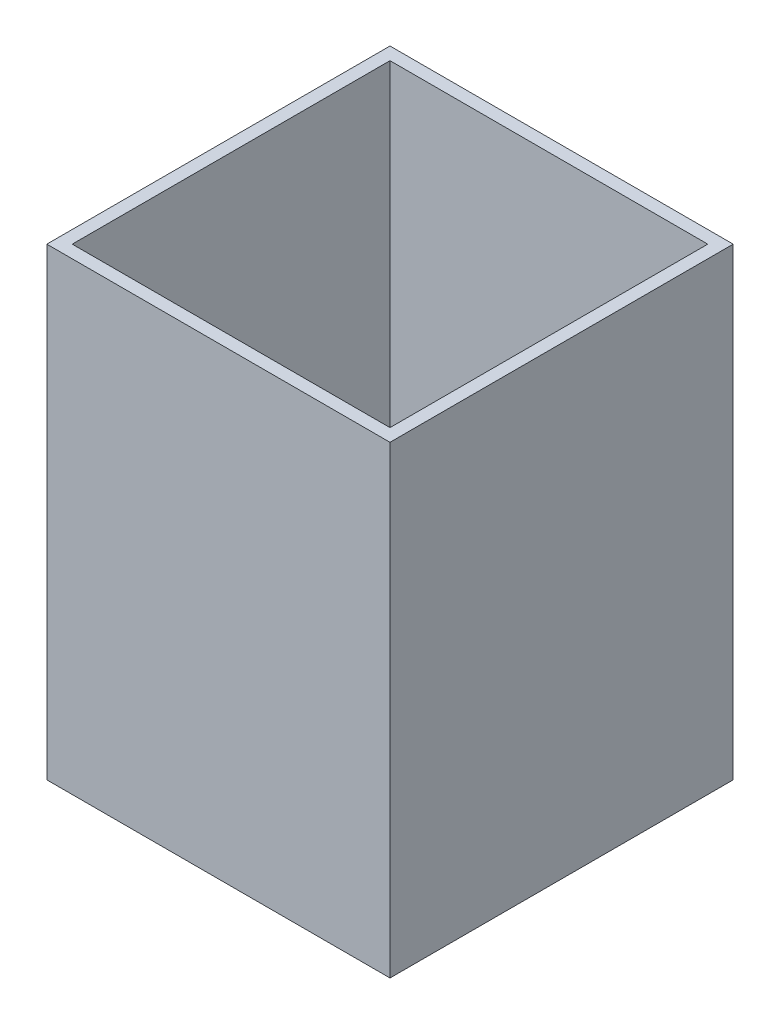
from build123d import *

# Parameters (mm, degrees)
SKETCH1_W           = 54
SKETCH1_H           = 54
SKETCH1_W_2         = 50
SKETCH1_H_2         = 50
BOSS_EXTRUDE1_DEPTH = 22
SKETCH2_W           = 54
SKETCH2_H           = 54
BOSS_EXTRUDE2_DEPTH = 1
SKETCH3_R           = 6
CUT_EXTRUDE1_DEPTH  = 24
SKETCH4_W           = 2
SKETCH4_H           = 50
SKETCH4_H_2         = 2
SKETCH4_W_2         = 50
BOSS_EXTRUDE3_DEPTH = 50


with BuildPart() as part:
    # Sketch1 → Boss-Extrude1 (new body)
    with BuildSketch(Plane(origin=(0, 0, 0), x_dir=(1, 0, 0), z_dir=(0, 1, 0))):
        Rectangle(SKETCH1_W, SKETCH1_H)
        Rectangle(SKETCH1_W_2, SKETCH1_H_2, mode=Mode.SUBTRACT)
    extrude(amount=BOSS_EXTRUDE1_DEPTH)

    # Sketch2 → Boss-Extrude2 (add)
    with BuildSketch(Plane(origin=(0, 22, 0), x_dir=(1, 0, 0), z_dir=(0, 1, 0))):
        Rectangle(SKETCH2_W, SKETCH2_H)
    extrude(amount=BOSS_EXTRUDE2_DEPTH)

    # Sketch3 → Cut-Extrude1 (cut, through all)
    with BuildSketch(Plane(origin=(0, 23, 0), x_dir=(1, 0, 0), z_dir=(0, 1, 0))):
        Circle(SKETCH3_R)
    extrude(amount=-CUT_EXTRUDE1_DEPTH, mode=Mode.SUBTRACT)

    # Sketch4 → Boss-Extrude3 (add)
    with BuildSketch(Plane(origin=(0, 23, 0), x_dir=(1, 0, 0), z_dir=(0, 1, 0))):
        with Locations((-26, 0)):
            Rectangle(SKETCH4_W, SKETCH4_H)
        with Locations((-26, -26)):
            Rectangle(SKETCH4_W, SKETCH4_H_2)
        with Locations((0, -26)):
            Rectangle(SKETCH4_W_2, SKETCH4_H_2)
        with Locations((26, -26)):
            Rectangle(SKETCH4_W, SKETCH4_H_2)
        with Locations((26, 0)):
            Rectangle(SKETCH4_W, SKETCH4_H)
        with Locations((26, 26)):
            Rectangle(SKETCH4_W, SKETCH4_H_2)
        with Locations((0, 26)):
            Rectangle(SKETCH4_W_2, SKETCH4_H_2)
        with Locations((-26, 26)):
            Rectangle(SKETCH4_W, SKETCH4_H_2)
    extrude(amount=BOSS_EXTRUDE3_DEPTH)


solid = part.part
